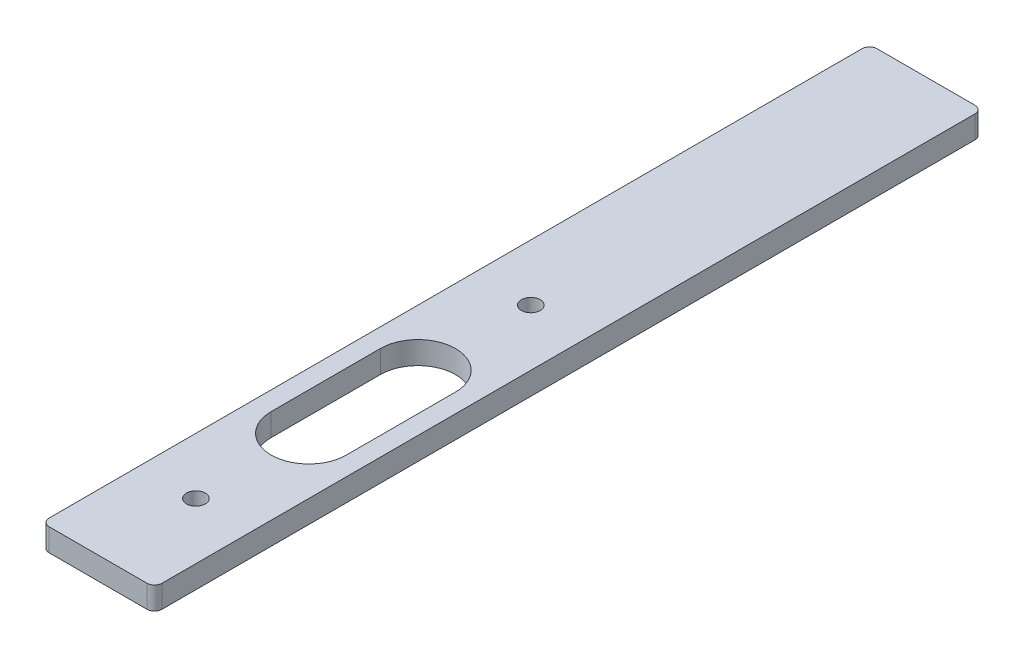
from build123d import *

# Parameters (mm, degrees)
SKETCH_1_W          = 15
SKETCH_1_H          = 110
EXTRUDE_1_DEPTH     = 3
FILLET_1_R          = 1
SKETCH_2_R          = 1.25
CUT_EXTRUDE_1_DEPTH = 3
CUT_EXTRUDE_2_DEPTH = 10


with BuildPart() as part:
    # 草图1 → 凸台-拉伸1 (new body)
    with BuildSketch(Plane(origin=(0, 0, 0), x_dir=(1, 0, 0), z_dir=(0, 1, 0))):
        with Locations((7.5, 55)):
            Rectangle(SKETCH_1_W, SKETCH_1_H)
    extrude(amount=EXTRUDE_1_DEPTH)

    # 圆角1
    fillet_1_edges = [part.edges().sort_by_distance(p)[0] for p in [
        (0, 1.5, -110),
        (15, 1.5, -110),
        (15, 1.5, 0),
        (0, 1.5, 0),
    ]]
    fillet(fillet_1_edges, radius=FILLET_1_R)

    # 草图2 → 切除-拉伸1 (cut)
    with BuildSketch(Plane(origin=(0, 3, 0), x_dir=(1, 0, 0), z_dir=(0, 1, 0))):
        with Locations((7.5, 13)):
            Circle(SKETCH_2_R)
        with Locations((7.5, 57.5)):
            Circle(SKETCH_2_R)
    extrude(amount=-CUT_EXTRUDE_1_DEPTH, mode=Mode.SUBTRACT)

    # 草图3 → 切除-拉伸2 (cut)
    with BuildSketch(Plane(origin=(0, 3, 0), x_dir=(1, 0, 0), z_dir=(0, 1, 0))):
        with BuildLine():
            Line((12.5, 42.5), (12.5, 28))
            ThreePointArc((12.5, 28), (7.5, 23), (2.5, 28))
            Line((2.5, 28), (2.5, 42.5))
            ThreePointArc((2.5, 42.5), (7.5, 47.5), (12.5, 42.5))
        make_face()
    extrude(amount=-CUT_EXTRUDE_2_DEPTH, mode=Mode.SUBTRACT)


solid = part.part
